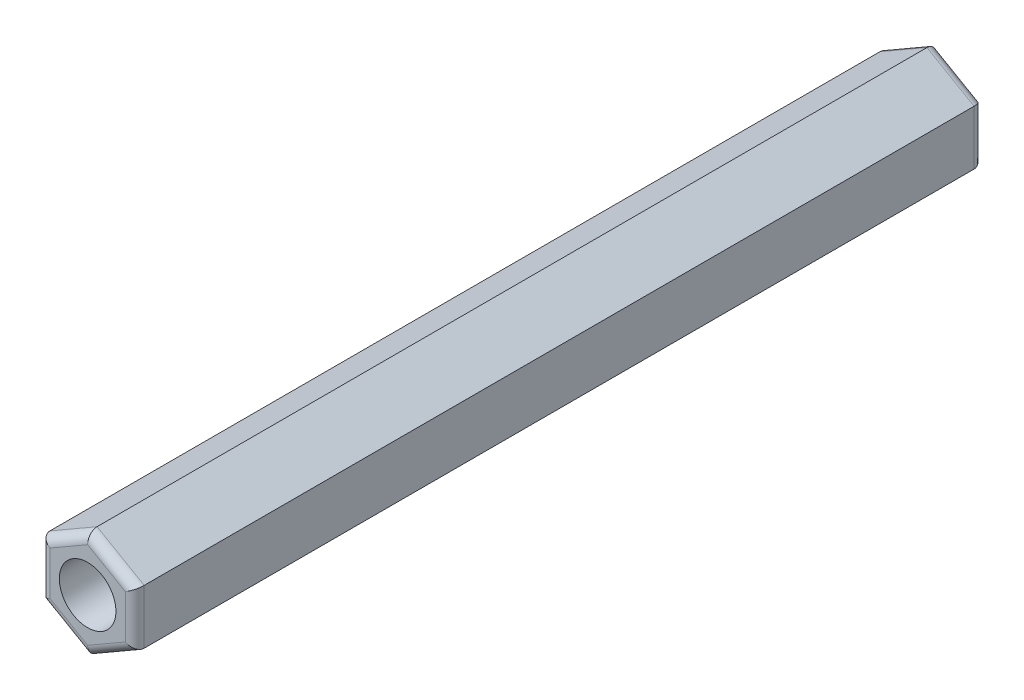
from build123d import *

# Parameters (mm, degrees)
RESSALTO_EXTRUS_O1_DEPTH = 45
FILETE1_R                = 0.5
ESBO_O2_R                = 1.5
CORTE_EXTRUS_O1_DEPTH    = 46


with BuildPart() as part:
    # Esboço1 → Ressalto-extrusão1 (new body)
    with BuildSketch(Plane(origin=(0, 0, 0), x_dir=(-1, 0, 0), z_dir=(0, 0, -1))):
        Polygon((67.502122675, -1.443375673), (70.002122675, -2.886751346), (72.502122675, -1.443375673), (72.502122675, 1.443375673), (70.002122675, 2.886751346), (67.502122675, 1.443375673), align=None)
    extrude(amount=-RESSALTO_EXTRUS_O1_DEPTH)

    # Filete1
    filete1_edges = [part.edges().sort_by_distance(p)[0] for p in [
        (-71.252122675, -2.165063509, 45),
        (-72.502122675, 0, 45),
        (-71.252122675, 2.165063509, 45),
        (-68.752122675, 2.165063509, 45),
        (-67.502122675, 0, 45),
        (-68.752122675, 2.165063509, 0),
        (-71.252122675, 2.165063509, 0),
        (-72.502122675, 0, 0),
        (-71.252122675, -2.165063509, 0),
        (-68.752122675, -2.165063509, 0),
        (-67.502122675, 0, 0),
        (-68.752122675, -2.165063509, 45),
    ]]
    fillet(filete1_edges, radius=FILETE1_R)

    # Esboço2 → Corte-extrusão1 (cut, through all)
    with BuildSketch(Plane.XY.offset(45)):
        with Locations((-70.002122675, 0)):
            Circle(ESBO_O2_R)
    extrude(amount=-CORTE_EXTRUS_O1_DEPTH, mode=Mode.SUBTRACT)


solid = part.part
